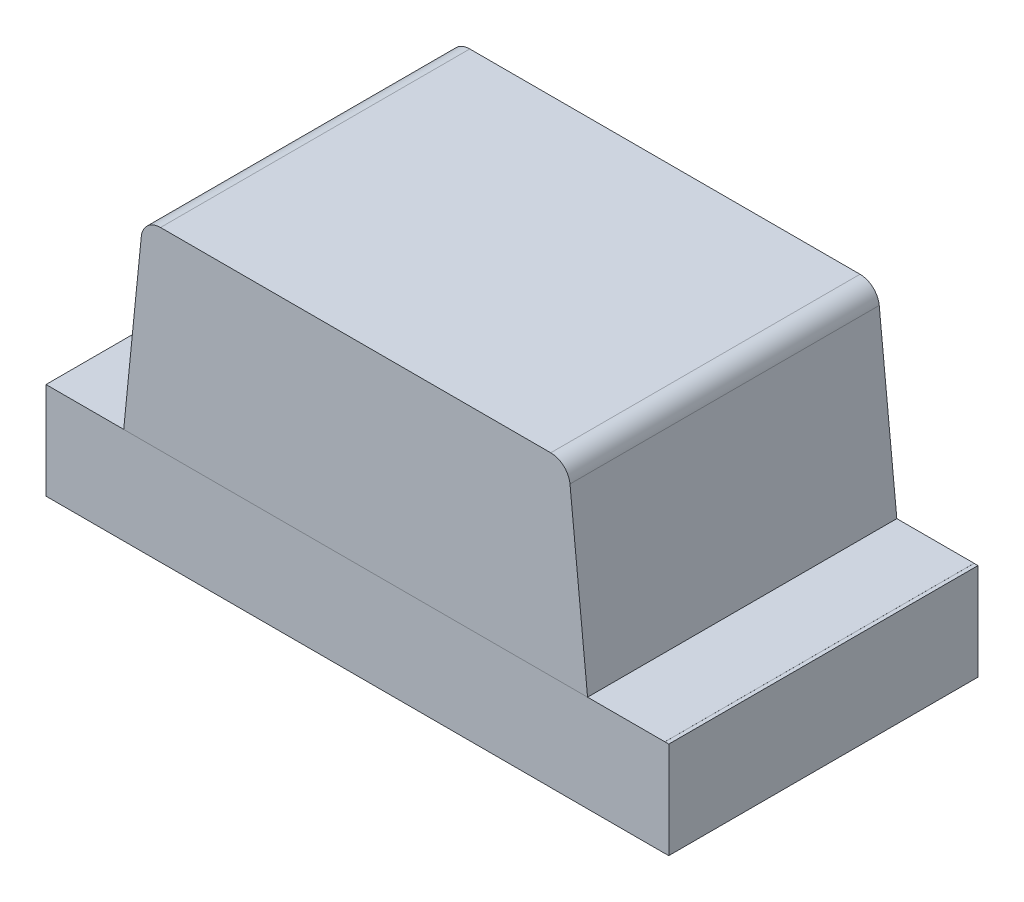
from build123d import *

# Parameters (mm, degrees)
SKETCH1_W             = 1.6
SKETCH1_H             = 0.25
EXTRUDE1_DEPTH        = 0.4
EXTRUDE2_DEPTH        = 0.4
EXTRUDE3_DEPTH        = 0.0001
EXTRUDE3_DEPTH_BACK   = 0.01
SKETCH2_3_W           = 0.3
SKETCH2_3_H           = 0.8
EXTRUDE4_DEPTH        = 0.0001
EXTRUDE4_DEPTH_BACK   = 0.01
EXTRUDE4_2_DEPTH      = 0.0001
EXTRUDE4_2_DEPTH_BACK = 0.01
SKETCH3_W             = 0.2
SKETCH3_H             = 0.8
EXTRUDE5_DEPTH        = 0.0001
EXTRUDE5_DEPTH_BACK   = 0.01
EXTRUDE5_2_DEPTH      = 0.0001
EXTRUDE5_2_DEPTH_BACK = 0.01
FILLET1_R             = 0.05
SKETCH5_W             = 0.8
SKETCH5_H             = 0.25
EXTRUDE6_DEPTH        = 0.01
EXTRUDE6_DEPTH_BACK   = 0.0001
SKETCH6_W             = 0.8
SKETCH6_H             = 0.2502
EXTRUDE7_DEPTH        = 0.001
EXTRUDE7_DEPTH_BACK   = 0.01
SKETCH7_W             = 0.013291139
SKETCH7_H             = 0.012658227
SKETCH7_H_2           = 0.012658228
CUT_EXTRUDE1_DEPTH    = 0.01


with BuildPart() as part:
    # Sketch1 → Extrude1 (new body, symmetric)
    with BuildSketch(Plane.XY):
        Rectangle(SKETCH1_W, SKETCH1_H)
    extrude(amount=EXTRUDE1_DEPTH, both=True)



with BuildPart() as body_2:
    # Sketch1_3 → Extrude2 (new body, symmetric)
    with BuildSketch(Plane.XY):
        Polygon((-0.55, 0.625), (-0.6, 0.125), (0.6, 0.125), (0.55, 0.625), align=None)
    extrude(amount=EXTRUDE2_DEPTH, both=True)

    # Fillet1
    fillet1_edges = [body_2.edges().sort_by_distance(p)[0] for p in [
        (-0.55, 0.625, 0),
        (0.55, 0.625, 0),
    ]]
    fillet(fillet1_edges, radius=FILLET1_R)


with BuildPart() as body_3:
    # Sketch2 → Extrude3 (new body, two sides)
    with BuildSketch(Plane.XZ.offset(0.125)) as extrude3_sk:
        Polygon((-0.339833711, 0.4), (-0.339833711, -0.4), (0.32532124, 0), align=None)
    extrude(amount=EXTRUDE3_DEPTH)
    extrude(extrude3_sk.sketch, amount=-EXTRUDE3_DEPTH_BACK)


with BuildPart() as body_4:
    # Sketch2_3 → Extrude4 (new body, two sides)
    with BuildSketch(Plane.XZ.offset(0.125)) as extrude4_sk:
        with Locations((-0.65, 0)):
            Rectangle(SKETCH2_3_W, SKETCH2_3_H)
    extrude(amount=EXTRUDE4_DEPTH)
    extrude(extrude4_sk.sketch, amount=-EXTRUDE4_DEPTH_BACK)


with BuildPart() as body_5:
    # Sketch2_3 → Extrude4 2 (new body, two sides)
    with BuildSketch(Plane.XZ.offset(0.125)) as extrude4_2_sk:
        with Locations((0.65, 0)):
            Rectangle(SKETCH2_3_W, SKETCH2_3_H)
    extrude(amount=EXTRUDE4_2_DEPTH)
    extrude(extrude4_2_sk.sketch, amount=-EXTRUDE4_2_DEPTH_BACK)


with BuildPart() as body_6:
    # Sketch3 → Extrude5 (new body, two sides)
    with BuildSketch(Plane(origin=(0, 0.125, 0), x_dir=(-1, 0, 0), z_dir=(0, 1, 0))) as extrude5_sk:
        with Locations((0.7, 0)):
            Rectangle(SKETCH3_W, SKETCH3_H)
    extrude(amount=EXTRUDE5_DEPTH)
    extrude(extrude5_sk.sketch, amount=-EXTRUDE5_DEPTH_BACK)


with BuildPart() as body_7:
    # Sketch3 → Extrude5 2 (new body, two sides)
    with BuildSketch(Plane(origin=(0, 0.125, 0), x_dir=(-1, 0, 0), z_dir=(0, 1, 0))) as extrude5_2_sk:
        with Locations((-0.7, 0)):
            Rectangle(SKETCH3_W, SKETCH3_H)
    extrude(amount=EXTRUDE5_2_DEPTH)
    extrude(extrude5_2_sk.sketch, amount=-EXTRUDE5_2_DEPTH_BACK)


with BuildPart() as part_1:
    add(part.part)

    add(body_5.part)  # Extrude6 merges body 5

    add(body_7.part)  # Extrude6 merges body 7
    # Sketch5 → Extrude6 (add, two sides)
    with BuildSketch(Plane(origin=(0.8, 0, 0), x_dir=(0, 0, -1), z_dir=(1, 0, 0))) as extrude6_sk:
        Rectangle(SKETCH5_W, SKETCH5_H)
    extrude(amount=EXTRUDE6_DEPTH)
    extrude(extrude6_sk.sketch, amount=-EXTRUDE6_DEPTH_BACK)


    add(body_4.part)  # Extrude7 merges body 4

    add(body_6.part)  # Extrude7 merges body 6
    # Sketch6 → Extrude7 (add, two sides)
    with BuildSketch(Plane.ZY.offset(0.8)) as extrude7_sk:
        Rectangle(SKETCH6_W, SKETCH6_H)
    extrude(amount=EXTRUDE7_DEPTH)
    extrude(extrude7_sk.sketch, amount=-EXTRUDE7_DEPTH_BACK)

    # Sketch7 → Cut-Extrude1 (cut)
    with BuildSketch(Plane.XZ.offset(0.1251)):
        Polygon((-0.707001992, 0.286075949), (-0.744343764, 0.297804589), (-0.744343764, 0.310176028), (-0.719175647, 0.318384098), (-0.744343764, 0.326147152), (-0.744343764, 0.339013054), (-0.707001992, 0.350632911), (-0.707001992, 0.338043908), (-0.732743685, 0.331546677), (-0.707001992, 0.323338608), (-0.707001992, 0.312589003), (-0.732743685, 0.30443038), (-0.707001992, 0.298022152), align=None)
        Polygon((-0.707001992, 0.218987342), (-0.744343764, 0.230715981), (-0.744343764, 0.243087421), (-0.719175647, 0.251295491), (-0.744343764, 0.259058544), (-0.744343764, 0.271924446), (-0.707001992, 0.283544304), (-0.707001992, 0.270955301), (-0.732743685, 0.26445807), (-0.707001992, 0.25625), (-0.707001992, 0.245500396), (-0.732743685, 0.237341772), (-0.707001992, 0.230933544), align=None)
        Polygon((-0.707001992, 0.151898734), (-0.744343764, 0.163627373), (-0.744343764, 0.175998813), (-0.719175647, 0.184206883), (-0.744343764, 0.191969937), (-0.744343764, 0.204835839), (-0.707001992, 0.216455696), (-0.707001992, 0.203866693), (-0.732743685, 0.197369462), (-0.707001992, 0.189161392), (-0.707001992, 0.178411788), (-0.732743685, 0.170253165), (-0.707001992, 0.163844937), align=None)
        with Locations((-0.737698195, 0.137974684)):
            Rectangle(SKETCH7_W, SKETCH7_H)
        with BuildLine():
            add(Edge.make_bspline(
                [(-0.728758321, 0.079746835), (-0.729369388, 0.079765085), (-0.73056932, 0.07980092), (-0.732323163, 0.080105713), (-0.733985315, 0.080602697), (-0.735567388, 0.081288866), (-0.737052132, 0.082185594), (-0.738453578, 0.08327723), (-0.73975585, 0.084571671), (-0.740974038, 0.086045073), (-0.742065093, 0.087693545), (-0.74301811, 0.089492402), (-0.743815446, 0.091432415), (-0.744484978, 0.093506521), (-0.744979195, 0.095729794), (-0.745341189, 0.098088543), (-0.745577848, 0.100585257), (-0.745598831, 0.102297046), (-0.745609587, 0.103174446)],
                knots=[0, 0, 0, 0, 0.907312236, 1.78165839, 2.635367075, 3.479697475, 4.336364812, 5.205276731, 6.11257575, 7.058770404, 8.040786331, 9.044147278, 10.078219212, 11.153049307, 12.278104542, 13.457648573, 14.696882856, 16, 16, 16, 16], degree=3))
            add(Edge.make_bspline(
                [(-0.745609587, 0.103174446), (-0.745597551, 0.104183574), (-0.745574239, 0.106138165), (-0.745359939, 0.108969928), (-0.74503687, 0.111603946), (-0.744553599, 0.114051804), (-0.743953216, 0.116354103), (-0.74330757, 0.118570737), (-0.742575363, 0.120711393), (-0.742025284, 0.122097938), (-0.741752783, 0.12278481)],
                knots=[0, 0, 0, 0, 1.203215828, 2.33052265, 3.384689099, 4.366106119, 5.303329643, 6.221311756, 7.118865988, 8, 8, 8, 8], degree=3))
            Line((-0.741752783, 0.12278481), (-0.729786802, 0.12278481))
            Line((-0.729786802, 0.12278481), (-0.729786802, 0.121360759))
            add(Edge.make_bspline(
                [(-0.729786802, 0.121360759), (-0.73032753, 0.120678102), (-0.73140581, 0.119316796), (-0.732787113, 0.11710018), (-0.733988194, 0.114776357), (-0.734975195, 0.112353621), (-0.735768357, 0.109905199), (-0.736315121, 0.10746751), (-0.736688795, 0.105084716), (-0.736729049, 0.103505432), (-0.736748828, 0.10272943)],
                knots=[0, 0, 0, 0, 1.030622468, 2.055194264, 3.087043286, 4.125157485, 5.149848264, 6.130935704, 7.081611712, 8, 8, 8, 8], degree=3))
            add(Edge.make_bspline(
                [(-0.736748828, 0.10272943), (-0.73674838, 0.102515041), (-0.736747423, 0.10205605), (-0.736683001, 0.101322032), (-0.73663642, 0.100492732), (-0.736531811, 0.099603299), (-0.736422519, 0.09870789), (-0.736232359, 0.09788056), (-0.73605144, 0.097128741), (-0.735867351, 0.0966755), (-0.735779682, 0.096459652)],
                knots=[0, 0, 0, 0, 0.806378557, 1.726393851, 2.771014456, 3.931269413, 5.096090628, 6.161710732, 7.124547685, 8, 8, 8, 8], degree=3))
            add(Edge.make_bspline(
                [(-0.735779682, 0.096459652), (-0.73566577, 0.096219758), (-0.735441909, 0.095748317), (-0.735033106, 0.095100857), (-0.734597455, 0.094509521), (-0.734114745, 0.093978791), (-0.733525791, 0.093553657), (-0.732825363, 0.093239557), (-0.732000213, 0.09306801), (-0.731412708, 0.093048363), (-0.731102071, 0.093037975)],
                knots=[0, 0, 0, 0, 1.024407818, 2.013179384, 2.949802342, 3.859052226, 4.77034807, 5.732977883, 6.801339628, 8, 8, 8, 8], degree=3))
            add(Edge.make_bspline(
                [(-0.731102071, 0.093037975), (-0.730829123, 0.093053696), (-0.730292427, 0.093084607), (-0.729528429, 0.093375503), (-0.72881749, 0.093816952), (-0.728187133, 0.094460463), (-0.727608414, 0.095257502), (-0.727123265, 0.09623537), (-0.726683228, 0.09736186), (-0.726474594, 0.098184089), (-0.726365125, 0.098615506)],
                knots=[0, 0, 0, 0, 0.825212765, 1.622611382, 2.449701629, 3.348069183, 4.336544339, 5.428209675, 6.6506027, 8, 8, 8, 8], degree=3))
            add(Edge.make_bspline(
                [(-0.726365125, 0.098615506), (-0.726141255, 0.09959987), (-0.72568266, 0.101616324), (-0.725109106, 0.104690378), (-0.72447607, 0.107755492), (-0.723871299, 0.109734848), (-0.723576359, 0.110700158)],
                knots=[0, 0, 0, 0, 0.976104583, 1.999535498, 3.024395274, 4, 4, 4, 4], degree=3))
            add(Edge.make_bspline(
                [(-0.723576359, 0.110700158), (-0.723399863, 0.111219416), (-0.723056296, 0.1122302), (-0.722475484, 0.113675972), (-0.721840508, 0.115006529), (-0.721162942, 0.116226584), (-0.720425943, 0.117326245), (-0.719659249, 0.11832384), (-0.71883233, 0.119195603), (-0.71796637, 0.119969445), (-0.717040369, 0.120631102), (-0.7160683, 0.121208477), (-0.715038068, 0.121696295), (-0.713957424, 0.122100736), (-0.712817989, 0.122409273), (-0.711629552, 0.122619901), (-0.710387872, 0.122769095), (-0.709540696, 0.122779501), (-0.7091084, 0.12278481)],
                knots=[0, 0, 0, 0, 1.287286806, 2.505824366, 3.654938963, 4.74627059, 5.778586806, 6.75996495, 7.696030012, 8.595059759, 9.482019644, 10.363222407, 11.245851011, 12.154256429, 13.068444161, 14.012503255, 14.985824751, 16, 16, 16, 16], degree=3))
            add(Edge.make_bspline(
                [(-0.7091084, 0.12278481), (-0.708530328, 0.122766159), (-0.707392692, 0.122729454), (-0.70572817, 0.12242874), (-0.704153801, 0.121915445), (-0.70265207, 0.121222413), (-0.701245527, 0.120308099), (-0.699906253, 0.119215702), (-0.698670457, 0.117903678), (-0.697520291, 0.116415118), (-0.696480591, 0.114771425), (-0.695565313, 0.113001934), (-0.694796987, 0.111117289), (-0.69416004, 0.109124516), (-0.693682705, 0.107015281), (-0.693323239, 0.104796665), (-0.693116648, 0.102459771), (-0.693091023, 0.10086406), (-0.693077942, 0.100049446)],
                knots=[0, 0, 0, 0, 0.894990994, 1.761326291, 2.609044902, 3.454222546, 4.315366365, 5.200560057, 6.125081389, 7.100429509, 8.110379559, 9.133447974, 10.182136699, 11.259192205, 12.370181258, 13.528580438, 14.738335141, 16, 16, 16, 16], degree=3))
            add(Edge.make_bspline(
                [(-0.693077942, 0.100049446), (-0.693089037, 0.099215103), (-0.69311121, 0.09754783), (-0.693300199, 0.095057109), (-0.693577813, 0.092576858), (-0.693998666, 0.090144943), (-0.694486874, 0.087799665), (-0.695034772, 0.085593047), (-0.695653754, 0.083553317), (-0.696130927, 0.082266485), (-0.696361169, 0.08164557)],
                knots=[0, 0, 0, 0, 1.065403572, 2.129000689, 3.188532477, 4.251604565, 5.279552602, 6.247508681, 7.154397237, 8, 8, 8, 8], degree=3))
            Line((-0.696361169, 0.08164557), (-0.707634904, 0.08164557))
            Line((-0.707634904, 0.08164557), (-0.707634904, 0.083059731))
            add(Edge.make_bspline(
                [(-0.707634904, 0.083059731), (-0.70723473, 0.083596183), (-0.706416365, 0.084693243), (-0.705374529, 0.086523061), (-0.704395596, 0.088502179), (-0.703553517, 0.090641594), (-0.702823776, 0.092871108), (-0.702314193, 0.095162587), (-0.701993288, 0.097475669), (-0.701956901, 0.099026524), (-0.701938701, 0.099802215)],
                knots=[0, 0, 0, 0, 0.892283326, 1.824742884, 2.804416662, 3.836872171, 4.8899239, 5.931447339, 6.965372909, 8, 8, 8, 8], degree=3))
            add(Edge.make_bspline(
                [(-0.701938701, 0.099802215), (-0.701949427, 0.100350049), (-0.701970878, 0.101445657), (-0.70216622, 0.103079762), (-0.702481667, 0.104700792), (-0.702891308, 0.105721053), (-0.703095742, 0.106230222)],
                knots=[0, 0, 0, 0, 0.999146175, 1.998183711, 3.000980573, 4, 4, 4, 4], degree=3))
            add(Edge.make_bspline(
                [(-0.703095742, 0.106230222), (-0.703196476, 0.106446973), (-0.703397875, 0.106880332), (-0.703784157, 0.107483654), (-0.704248563, 0.108035989), (-0.704774559, 0.108532027), (-0.705352745, 0.108966226), (-0.705990159, 0.109273902), (-0.706671616, 0.109461838), (-0.707139231, 0.109482917), (-0.707377783, 0.109493671)],
                knots=[0, 0, 0, 0, 1.00524851, 2.009826503, 3.004679593, 4.035271301, 5.048246368, 6.034938417, 6.997532266, 8, 8, 8, 8], degree=3))
            add(Edge.make_bspline(
                [(-0.707377783, 0.109493671), (-0.707696866, 0.109476452), (-0.708306604, 0.109443548), (-0.709164502, 0.109140256), (-0.709903719, 0.108647839), (-0.710401179, 0.108067536), (-0.710749898, 0.107508972), (-0.711005153, 0.106991142), (-0.711246832, 0.106386528), (-0.711495567, 0.105700905), (-0.71174116, 0.104932741), (-0.711978934, 0.104078462), (-0.712203582, 0.103137104), (-0.712346677, 0.102479167), (-0.712421296, 0.102136076)],
                knots=[0, 0, 0, 0, 1.173816843, 2.243057204, 3.312297565, 4.415174738, 5.03266065, 5.73970059, 6.541434878, 7.433956553, 8.430083051, 9.515931566, 10.70464786, 12, 12, 12, 12], degree=3))
            add(Edge.make_bspline(
                [(-0.712421296, 0.102136076), (-0.712609327, 0.101219681), (-0.712978766, 0.099419168), (-0.71353051, 0.096718577), (-0.714167994, 0.09396719), (-0.714742396, 0.092134526), (-0.715041945, 0.091178797)],
                knots=[0, 0, 0, 0, 0.995744513, 1.956417928, 2.934277412, 4, 4, 4, 4], degree=3))
            add(Edge.make_bspline(
                [(-0.715041945, 0.091178797), (-0.715201567, 0.09070552), (-0.715513813, 0.089779714), (-0.716056954, 0.088459399), (-0.716643946, 0.087235869), (-0.717264711, 0.086102353), (-0.717936694, 0.085065368), (-0.718648018, 0.084118027), (-0.719411472, 0.083276117), (-0.720218086, 0.082527335), (-0.721073136, 0.081867755), (-0.721992673, 0.081301606), (-0.722967074, 0.080815492), (-0.724010174, 0.080430689), (-0.725107467, 0.080121679), (-0.726273151, 0.079910131), (-0.72749534, 0.079763139), (-0.728332628, 0.079752331), (-0.728758321, 0.079746835)],
                knots=[0, 0, 0, 0, 1.237467875, 2.420686895, 3.535046182, 4.599015201, 5.620884487, 6.594603852, 7.531477383, 8.433220087, 9.318759595, 10.202828513, 11.105163009, 12.01247538, 12.953896178, 13.926381251, 14.945733412, 16, 16, 16, 16], degree=3))
        make_face()
        with BuildLine():
            Line((-0.744343764, 0.033544304), (-0.744343764, 0.04556962))
            Line((-0.744343764, 0.04556962), (-0.740427625, 0.04556962))
            add(Edge.make_bspline(
                [(-0.740427625, 0.04556962), (-0.740831904, 0.046116275), (-0.741611349, 0.047170216), (-0.742651457, 0.048756729), (-0.74353909, 0.050269774), (-0.744318701, 0.051726519), (-0.744906393, 0.053237621), (-0.745320427, 0.054853378), (-0.745570313, 0.05660479), (-0.745596205, 0.057818238), (-0.745609587, 0.058445411)],
                knots=[0, 0, 0, 0, 1.150872466, 2.218865267, 3.209461834, 4.120482262, 5.012764827, 5.946708227, 6.938749913, 8, 8, 8, 8], degree=3))
            add(Edge.make_bspline(
                [(-0.745609587, 0.058445411), (-0.745598228, 0.058953587), (-0.745576107, 0.059943153), (-0.745403669, 0.061381773), (-0.745134843, 0.062735587), (-0.744731047, 0.063993106), (-0.744248146, 0.065175101), (-0.743608167, 0.066243876), (-0.74289308, 0.067245677), (-0.742039557, 0.068136513), (-0.74109069, 0.068944324), (-0.74002446, 0.069635599), (-0.738857998, 0.070224454), (-0.737582071, 0.070695003), (-0.736202919, 0.071072548), (-0.734713295, 0.071334514), (-0.733119731, 0.07149481), (-0.732022166, 0.07151078), (-0.731458084, 0.071518987)],
                knots=[0, 0, 0, 0, 1.109008058, 2.159558935, 3.158726032, 4.116861086, 5.039058877, 5.938775559, 6.82970133, 7.720510853, 8.624361809, 9.544451588, 10.487360536, 11.471068125, 12.508000841, 13.604731202, 14.768976642, 16, 16, 16, 16], degree=3))
            Line((-0.731458084, 0.071518987), (-0.707001992, 0.071518987))
            Line((-0.707001992, 0.071518987), (-0.707001992, 0.059493671))
            Line((-0.707001992, 0.059493671), (-0.725791549, 0.059493671))
            add(Edge.make_bspline(
                [(-0.725791549, 0.059493671), (-0.726249785, 0.059492853), (-0.727126892, 0.059491288), (-0.728379796, 0.059450118), (-0.729513882, 0.059389668), (-0.730534896, 0.059320316), (-0.731458272, 0.059193807), (-0.732291352, 0.059004953), (-0.733051153, 0.05876954), (-0.733504504, 0.058537381), (-0.73372272, 0.058425633)],
                knots=[0, 0, 0, 0, 1.361401701, 2.605856924, 3.723918663, 4.735739235, 5.645738665, 6.489217889, 7.27279937, 8, 8, 8, 8], degree=3))
            add(Edge.make_bspline(
                [(-0.73372272, 0.058425633), (-0.733922077, 0.05831063), (-0.734313997, 0.058084543), (-0.734817086, 0.057624398), (-0.73523922, 0.057085026), (-0.735567234, 0.056446225), (-0.735816709, 0.055702951), (-0.735986827, 0.054838985), (-0.736094578, 0.053846304), (-0.736108532, 0.053141795), (-0.736115916, 0.052768987)],
                knots=[0, 0, 0, 0, 0.849138082, 1.669332372, 2.503455908, 3.370611167, 4.311442699, 5.394692208, 6.621337967, 8, 8, 8, 8], degree=3))
            add(Edge.make_bspline(
                [(-0.736115916, 0.052768987), (-0.736107238, 0.052498345), (-0.736089394, 0.051941887), (-0.735973171, 0.05108623), (-0.735794834, 0.050187942), (-0.735464906, 0.04893065), (-0.734871816, 0.047347337), (-0.734194613, 0.046167686), (-0.73385128, 0.04556962)],
                knots=[0, 0, 0, 0, 0.638127216, 1.312033637, 2.033062677, 2.79661882, 4.375931797, 6, 6, 6, 6], degree=3))
            Line((-0.73385128, 0.04556962), (-0.707001992, 0.04556962))
            Line((-0.707001992, 0.04556962), (-0.707001992, 0.033544304))
            Line((-0.707001992, 0.033544304), (-0.744343764, 0.033544304))
        make_face()
        with BuildLine():
            Line((-0.744343764, -0.015189873), (-0.744343764, -0.003164557))
            Line((-0.744343764, -0.003164557), (-0.725554207, -0.003164557))
            add(Edge.make_bspline(
                [(-0.725554207, -0.003164557), (-0.724789186, -0.0031523), (-0.723263673, -0.003127858), (-0.721382468, -0.002986796), (-0.719961306, -0.002797535), (-0.719042365, -0.002612707), (-0.718268296, -0.002396857), (-0.717825416, -0.002190717), (-0.717623036, -0.002096519)],
                knots=[0, 0, 0, 0, 1.709124929, 3.408128882, 4.211124727, 4.91016634, 5.501986363, 6, 6, 6, 6], degree=3))
            add(Edge.make_bspline(
                [(-0.717623036, -0.002096519), (-0.71742401, -0.001974288), (-0.71703379, -0.001734636), (-0.716527283, -0.001265974), (-0.716112863, -0.000719031), (-0.715772088, -8.3646e-05), (-0.715536797, 0.000661952), (-0.715340182, 0.001520323), (-0.715256728, 0.002513632), (-0.715239148, 0.003217267), (-0.71522984, 0.003589794)],
                knots=[0, 0, 0, 0, 0.86006424, 1.686277094, 2.52783008, 3.38194165, 4.331801563, 5.402842185, 6.624978739, 8, 8, 8, 8], degree=3))
            add(Edge.make_bspline(
                [(-0.71522984, 0.003589794), (-0.715258209, 0.004155705), (-0.715316136, 0.005311252), (-0.715671889, 0.006742349), (-0.716081369, 0.007907651), (-0.716460784, 0.008833913), (-0.716946505, 0.009788229), (-0.717307416, 0.010427935), (-0.717494476, 0.010759494)],
                knots=[0, 0, 0, 0, 1.338371478, 2.732853438, 3.468019217, 4.261884641, 5.099136535, 6, 6, 6, 6], degree=3))
            Line((-0.717494476, 0.010759494), (-0.744343764, 0.010759494))
            Line((-0.744343764, 0.010759494), (-0.744343764, 0.02278481))
            Line((-0.744343764, 0.02278481), (-0.707001992, 0.02278481))
            Line((-0.707001992, 0.02278481), (-0.707001992, 0.010759494))
            Line((-0.707001992, 0.010759494), (-0.710918131, 0.010759494))
            add(Edge.make_bspline(
                [(-0.710918131, 0.010759494), (-0.710515056, 0.01023079), (-0.709730445, 0.009201638), (-0.708710234, 0.007612019), (-0.70781085, 0.00607007), (-0.707054441, 0.004543565), (-0.706451054, 0.002986088), (-0.706045559, 0.001354709), (-0.705773658, -0.000353494), (-0.705748811, -0.001521852), (-0.705736169, -0.002116297)],
                knots=[0, 0, 0, 0, 1.126119141, 2.192057864, 3.198061997, 4.149848529, 5.076251285, 6.021887753, 6.99356175, 8, 8, 8, 8], degree=3))
            add(Edge.make_bspline(
                [(-0.705736169, -0.002116297), (-0.705748864, -0.002614433), (-0.705773646, -0.003586883), (-0.705928501, -0.005004263), (-0.706203833, -0.006339973), (-0.706602748, -0.00758611), (-0.707095554, -0.00875742), (-0.707711311, -0.009838393), (-0.708440523, -0.010834428), (-0.709271024, -0.011748628), (-0.710215887, -0.012564037), (-0.711274519, -0.013272555), (-0.712446068, -0.013862546), (-0.713726222, -0.014347902), (-0.715108777, -0.014735114), (-0.716606759, -0.014992679), (-0.718208849, -0.015169571), (-0.71931687, -0.015182971), (-0.719887673, -0.015189873)],
                knots=[0, 0, 0, 0, 1.08848837, 2.124922927, 3.110950502, 4.063144162, 4.979605775, 5.882838355, 6.774625441, 7.671951181, 8.57587277, 9.494821853, 10.448322275, 11.435533005, 12.482327682, 13.580118324, 14.753386918, 16, 16, 16, 16], degree=3))
            Line((-0.719887673, -0.015189873), (-0.744343764, -0.015189873))
        make_face()
        Polygon((-0.744343764, -0.062658228), (-0.744343764, -0.026582278), (-0.694343764, -0.026582278), (-0.694343764, -0.039240506), (-0.734850093, -0.039240506), (-0.734850093, -0.062658228), align=None)
        Polygon((-0.744343764, -0.106329114), (-0.744343764, -0.070253165), (-0.694343764, -0.070253165), (-0.694343764, -0.106329114), (-0.703837435, -0.106329114), (-0.703837435, -0.082911392), (-0.712698195, -0.082911392), (-0.712698195, -0.10443038), (-0.722191866, -0.10443038), (-0.722191866, -0.082911392), (-0.734850093, -0.082911392), (-0.734850093, -0.106329114), align=None)
        with BuildLine():
            add(Edge.make_bspline(
                [(-0.719393211, -0.164556962), (-0.719967055, -0.164547304), (-0.721103498, -0.164528178), (-0.722785901, -0.164380583), (-0.724418739, -0.16411757), (-0.726010863, -0.163777979), (-0.727550327, -0.163316726), (-0.729054116, -0.16277587), (-0.730506863, -0.162121047), (-0.73190758, -0.16136862), (-0.733243631, -0.160543884), (-0.734503736, -0.15965651), (-0.735695344, -0.15873362), (-0.736792791, -0.157738964), (-0.737813801, -0.156699373), (-0.738759208, -0.155611609), (-0.739610924, -0.154459076), (-0.740122366, -0.153655495), (-0.740378179, -0.15325356)],
                knots=[0, 0, 0, 0, 1.105570398, 2.18947457, 3.250358341, 4.290584537, 5.323553275, 6.344225964, 7.367641686, 8.3905646, 9.405808457, 10.390761353, 11.358902336, 12.307789878, 13.241960776, 14.165076779, 15.082208636, 16, 16, 16, 16], degree=3))
            add(Edge.make_bspline(
                [(-0.740378179, -0.15325356), (-0.740734249, -0.152633946), (-0.741448205, -0.151391556), (-0.7422825, -0.149399639), (-0.742984558, -0.147336898), (-0.74351177, -0.145161705), (-0.743875292, -0.1428382), (-0.744155696, -0.140337495), (-0.744306575, -0.1376337), (-0.744331085, -0.135766253), (-0.744343764, -0.134800237)],
                knots=[0, 0, 0, 0, 0.896288622, 1.797150563, 2.705281913, 3.629615989, 4.602417572, 5.655716007, 6.787320449, 8, 8, 8, 8], degree=3))
            Line((-0.744343764, -0.134800237), (-0.744343764, -0.117088608))
            Line((-0.744343764, -0.117088608), (-0.694343764, -0.117088608))
            Line((-0.694343764, -0.117088608), (-0.694343764, -0.135304589))
            add(Edge.make_bspline(
                [(-0.694343764, -0.135304589), (-0.69435207, -0.136293955), (-0.69436809, -0.138202319), (-0.694576885, -0.140960738), (-0.694875297, -0.143513342), (-0.695337733, -0.145856016), (-0.695895405, -0.148006019), (-0.69657497, -0.149968756), (-0.697324323, -0.151774643), (-0.69796117, -0.152864064), (-0.698269793, -0.153392009)],
                knots=[0, 0, 0, 0, 1.267175336, 2.444223962, 3.542125549, 4.557526608, 5.500936977, 6.385043188, 7.217374394, 8, 8, 8, 8], degree=3))
            add(Edge.make_bspline(
                [(-0.698269793, -0.153392009), (-0.698538063, -0.153817486), (-0.69907152, -0.154663548), (-0.699962446, -0.155864156), (-0.700940485, -0.156978869), (-0.701966394, -0.158043121), (-0.703067837, -0.15903303), (-0.704237191, -0.159954629), (-0.705476238, -0.160806538), (-0.706780972, -0.16158552), (-0.708145998, -0.162295927), (-0.709582528, -0.16289058), (-0.711071793, -0.163415255), (-0.712626274, -0.163818023), (-0.714230192, -0.16416698), (-0.715900864, -0.164384347), (-0.717627108, -0.164527653), (-0.718799553, -0.16454711), (-0.719393211, -0.164556962)],
                knots=[0, 0, 0, 0, 0.964065863, 1.917049184, 2.86229036, 3.805247319, 4.749389377, 5.698846072, 6.657678277, 7.629829384, 8.610569287, 9.604676042, 10.607940105, 11.6349849, 12.681042988, 13.752616828, 14.862056989, 16, 16, 16, 16], degree=3))
        make_face()
        with BuildLine():
            add(Edge.make_bspline(
                [(-0.719314097, -0.151265823), (-0.718911717, -0.151260702), (-0.718122425, -0.151250659), (-0.716964667, -0.151154875), (-0.715849842, -0.151025347), (-0.714782496, -0.15080982), (-0.713752711, -0.150559996), (-0.712773964, -0.150238922), (-0.711834177, -0.149876723), (-0.710945433, -0.149435904), (-0.710091242, -0.148949086), (-0.709298484, -0.148375339), (-0.708542041, -0.14775117), (-0.707828049, -0.147062027), (-0.707175101, -0.146290557), (-0.706560063, -0.145460506), (-0.7059959, -0.144560327), (-0.705665875, -0.143923833), (-0.705498828, -0.143601661)],
                knots=[0, 0, 0, 0, 1.152093354, 2.259898929, 3.325467225, 4.364140538, 5.376172865, 6.358396836, 7.312077728, 8.257828931, 9.196960457, 10.124297759, 11.056236784, 12.004246951, 12.961658638, 13.947279359, 14.960983522, 16, 16, 16, 16], degree=3))
            add(Edge.make_bspline(
                [(-0.705498828, -0.143601661), (-0.705345472, -0.143264213), (-0.705041509, -0.142595365), (-0.704675913, -0.141559954), (-0.704389495, -0.140515262), (-0.704174066, -0.139414463), (-0.704013101, -0.138179583), (-0.703914472, -0.136716792), (-0.703843387, -0.134988837), (-0.703839511, -0.13374548), (-0.703837435, -0.133079509)],
                knots=[0, 0, 0, 0, 0.826967603, 1.639107464, 2.447640171, 3.242670507, 4.14065217, 5.225198036, 6.513753944, 8, 8, 8, 8], degree=3))
            Line((-0.703837435, -0.133079509), (-0.703837435, -0.129746835))
            Line((-0.703837435, -0.129746835), (-0.734850093, -0.129746835))
            Line((-0.734850093, -0.129746835), (-0.734850093, -0.133079509))
            add(Edge.make_bspline(
                [(-0.734850093, -0.133079509), (-0.734847719, -0.133458613), (-0.734843134, -0.134190496), (-0.734821603, -0.135248617), (-0.734798159, -0.136231516), (-0.734739928, -0.137133951), (-0.734703605, -0.137963293), (-0.734614415, -0.138706684), (-0.734543325, -0.139377929), (-0.734409464, -0.140161727), (-0.734201372, -0.14108831), (-0.733862283, -0.14216894), (-0.733437085, -0.143239207), (-0.733094602, -0.143933494), (-0.732921692, -0.144284019)],
                knots=[0, 0, 0, 0, 1.186793418, 2.291178421, 3.313283093, 4.264083014, 5.122158624, 5.910777728, 6.607099052, 7.234812932, 8.398911528, 9.577194775, 10.776795607, 12, 12, 12, 12], degree=3))
            add(Edge.make_bspline(
                [(-0.732921692, -0.144284019), (-0.732750933, -0.144576577), (-0.732414176, -0.14515354), (-0.731847139, -0.145965292), (-0.731243277, -0.146719151), (-0.730599051, -0.147417157), (-0.729904931, -0.148048807), (-0.72917166, -0.148624816), (-0.728397671, -0.149140041), (-0.727300912, -0.149757735), (-0.725785444, -0.150369358), (-0.72380175, -0.15088913), (-0.721621869, -0.151207565), (-0.72010306, -0.151245906), (-0.719314097, -0.151265823)],
                knots=[0, 0, 0, 0, 0.755160452, 1.489275589, 2.205657296, 2.907868421, 3.605098304, 4.296256403, 4.985378686, 5.676536785, 7.100390329, 8.614249252, 10.241231541, 12, 12, 12, 12], degree=3))
        make_face(mode=Mode.SUBTRACT)
        with Locations((-0.737698195, -0.180379747)):
            Rectangle(SKETCH7_W, SKETCH7_H_2)
        with BuildLine():
            add(Edge.make_bspline(
                [(-0.745609587, -0.217701741), (-0.745598682, -0.216906684), (-0.745577276, -0.215346116), (-0.745338817, -0.213060445), (-0.74497997, -0.210877859), (-0.744469516, -0.208804705), (-0.743795768, -0.206847809), (-0.7429693, -0.20501599), (-0.741976708, -0.203312562), (-0.741187104, -0.202283238), (-0.740793527, -0.201770174)],
                knots=[0, 0, 0, 0, 1.123670284, 2.205584497, 3.245308791, 4.249063313, 5.220352711, 6.167273909, 7.086481357, 8, 8, 8, 8], degree=3))
            add(Edge.make_bspline(
                [(-0.740793527, -0.201770174), (-0.74036614, -0.2012943), (-0.739513018, -0.200344393), (-0.738027305, -0.199111426), (-0.736385783, -0.198049884), (-0.734584672, -0.197157107), (-0.732626307, -0.196441646), (-0.730503976, -0.195930079), (-0.728223586, -0.195620456), (-0.726649619, -0.195586873), (-0.725840995, -0.19556962)],
                knots=[0, 0, 0, 0, 0.916457077, 1.82937027, 2.759194969, 3.714948755, 4.706655623, 5.743329475, 6.840637961, 8, 8, 8, 8], degree=3))
            add(Edge.make_bspline(
                [(-0.725840995, -0.19556962), (-0.724989382, -0.195589), (-0.723338842, -0.195626562), (-0.720952748, -0.195958442), (-0.718743908, -0.196493248), (-0.716717954, -0.197262027), (-0.714871358, -0.198227248), (-0.71318544, -0.199359494), (-0.711663978, -0.200669757), (-0.710791259, -0.201673326), (-0.710354445, -0.202175633)],
                knots=[0, 0, 0, 0, 1.171797512, 2.271099083, 3.308930235, 4.294129479, 5.24602549, 6.17106565, 7.084581485, 8, 8, 8, 8], degree=3))
            add(Edge.make_bspline(
                [(-0.710354445, -0.202175633), (-0.709970152, -0.202688568), (-0.709196924, -0.203720634), (-0.708246574, -0.205422386), (-0.707449181, -0.207233994), (-0.706825359, -0.209148779), (-0.706348406, -0.211135184), (-0.705986484, -0.213165013), (-0.705776205, -0.21523814), (-0.705749579, -0.21663324), (-0.705736169, -0.217335839)],
                knots=[0, 0, 0, 0, 0.952130878, 1.915761808, 2.890227217, 3.891541892, 4.905612075, 5.925811839, 6.955400088, 8, 8, 8, 8], degree=3))
            add(Edge.make_bspline(
                [(-0.705736169, -0.217335839), (-0.705744671, -0.217959198), (-0.705761387, -0.219184934), (-0.705922441, -0.220985457), (-0.706189001, -0.222712728), (-0.706558302, -0.224365194), (-0.707004104, -0.225952167), (-0.707523674, -0.227477255), (-0.708090308, -0.228957161), (-0.708532576, -0.229907445), (-0.708752388, -0.230379747)],
                knots=[0, 0, 0, 0, 1.107648782, 2.178012834, 3.209595929, 4.211695017, 5.185427128, 6.137685403, 7.07440854, 8, 8, 8, 8], degree=3))
            Line((-0.708752388, -0.230379747), (-0.719027309, -0.230379747))
            Line((-0.719027309, -0.230379747), (-0.719027309, -0.228708465))
            add(Edge.make_bspline(
                [(-0.719027309, -0.228708465), (-0.718818699, -0.228458693), (-0.718367842, -0.227918875), (-0.717657465, -0.227025667), (-0.716892669, -0.225951196), (-0.716446696, -0.225124428), (-0.716208875, -0.224683544)],
                knots=[0, 0, 0, 0, 0.792826818, 1.713491785, 2.780691913, 4, 4, 4, 4], degree=3))
            add(Edge.make_bspline(
                [(-0.716208875, -0.224683544), (-0.715987896, -0.224219577), (-0.715534966, -0.223268604), (-0.715118549, -0.221990602), (-0.714834686, -0.220894601), (-0.714706475, -0.219985833), (-0.714611695, -0.219019023), (-0.714601941, -0.218351402), (-0.714596929, -0.218008307)],
                knots=[0, 0, 0, 0, 1.332524827, 2.731214173, 3.480270227, 4.267952375, 5.109889624, 6, 6, 6, 6], degree=3))
            add(Edge.make_bspline(
                [(-0.714596929, -0.218008307), (-0.714606704, -0.217625529), (-0.714625647, -0.216883724), (-0.714764175, -0.21580297), (-0.715003304, -0.214793764), (-0.715323354, -0.213842153), (-0.71576716, -0.212973121), (-0.716283979, -0.212159701), (-0.71689688, -0.211413572), (-0.717617351, -0.210753941), (-0.718407315, -0.210157578), (-0.719274373, -0.209647977), (-0.720197673, -0.209191749), (-0.721199897, -0.20884428), (-0.722264285, -0.208564411), (-0.723395845, -0.208369946), (-0.7245956, -0.208248967), (-0.725418754, -0.208235008), (-0.725840995, -0.208227848)],
                knots=[0, 0, 0, 0, 1.087302107, 2.107140881, 3.088415001, 4.030197574, 4.951552271, 5.852940509, 6.764198256, 7.685219758, 8.621679636, 9.570836121, 10.538340132, 11.542450476, 12.578202196, 13.66207107, 14.800746211, 16, 16, 16, 16], degree=3))
            add(Edge.make_bspline(
                [(-0.725840995, -0.208227848), (-0.726273074, -0.208235235), (-0.72711258, -0.208249588), (-0.728333385, -0.208366345), (-0.729474101, -0.208574291), (-0.730536761, -0.208859915), (-0.73151977, -0.209222089), (-0.732418468, -0.209674648), (-0.733246872, -0.210192826), (-0.733978178, -0.210815105), (-0.734636339, -0.211497047), (-0.735204406, -0.212254492), (-0.735678478, -0.213084112), (-0.73608071, -0.213975202), (-0.736369909, -0.214941723), (-0.736588255, -0.215969991), (-0.736732533, -0.217064769), (-0.736743315, -0.217819945), (-0.736748828, -0.218206092)],
                knots=[0, 0, 0, 0, 1.230336593, 2.390482092, 3.487897344, 4.52859895, 5.520747884, 6.465347575, 7.38981449, 8.296085817, 9.192433006, 10.084246191, 10.984321635, 11.908883871, 12.862027947, 13.850751296, 14.901019963, 16, 16, 16, 16], degree=3))
            add(Edge.make_bspline(
                [(-0.736748828, -0.218206092), (-0.736744764, -0.218569019), (-0.736736842, -0.219276532), (-0.736627803, -0.220308905), (-0.736489862, -0.221289359), (-0.736270158, -0.222207129), (-0.735998971, -0.223054762), (-0.735715717, -0.223834974), (-0.735413325, -0.224541197), (-0.735179548, -0.224971874), (-0.735067657, -0.225178006)],
                knots=[0, 0, 0, 0, 1.200823684, 2.340960236, 3.433630075, 4.476504061, 5.46014544, 6.378484521, 7.223905657, 8, 8, 8, 8], degree=3))
            add(Edge.make_bspline(
                [(-0.735067657, -0.225178006), (-0.73485271, -0.225528109), (-0.734436888, -0.226205393), (-0.733736105, -0.227124757), (-0.733028976, -0.227947191), (-0.732550867, -0.228459447), (-0.732318448, -0.228708465)],
                knots=[0, 0, 0, 0, 1.098601379, 2.125273733, 3.088655601, 4, 4, 4, 4], degree=3))
            Line((-0.732318448, -0.228708465), (-0.732318448, -0.230379747))
            Line((-0.732318448, -0.230379747), (-0.742672483, -0.230379747))
            add(Edge.make_bspline(
                [(-0.742672483, -0.230379747), (-0.74289123, -0.229907052), (-0.743328777, -0.228961548), (-0.743905713, -0.227504259), (-0.744389793, -0.226010272), (-0.744841333, -0.224486086), (-0.745185514, -0.222900044), (-0.745432075, -0.221238529), (-0.745582531, -0.21949778), (-0.745600446, -0.218308585), (-0.745609587, -0.217701741)],
                knots=[0, 0, 0, 0, 0.952012952, 1.904254716, 2.862729541, 3.822037426, 4.808956931, 5.82647221, 6.890850784, 8, 8, 8, 8], degree=3))
        make_face()
        with BuildLine():
            add(Edge.make_bspline(
                [(-0.725692657, -0.276582278), (-0.72644511, -0.276569931), (-0.727911843, -0.276545862), (-0.730047738, -0.276276203), (-0.732065737, -0.275869813), (-0.733959341, -0.275283548), (-0.735737979, -0.274543352), (-0.737382875, -0.273617882), (-0.73890949, -0.27253238), (-0.740304432, -0.271286861), (-0.741553687, -0.26988626), (-0.742651314, -0.268349169), (-0.743558035, -0.266662255), (-0.74431408, -0.2648551), (-0.744898698, -0.262912774), (-0.745305056, -0.260835664), (-0.745572791, -0.258627097), (-0.745597117, -0.257107888), (-0.745609587, -0.256329114)],
                knots=[0, 0, 0, 0, 1.120167703, 2.183507516, 3.201345984, 4.182878364, 5.131270247, 6.065524964, 6.98789854, 7.91635504, 8.84481154, 9.778033504, 10.722808862, 11.691211189, 12.691525459, 13.738229926, 14.840575679, 16, 16, 16, 16], degree=3))
            add(Edge.make_bspline(
                [(-0.745609587, -0.256329114), (-0.745597076, -0.255550353), (-0.74557267, -0.254031171), (-0.745305504, -0.251822416), (-0.744896529, -0.249742868), (-0.744318478, -0.247798215), (-0.743555204, -0.245993842), (-0.74265168, -0.244308909), (-0.741553583, -0.242772026), (-0.740304487, -0.241371283), (-0.738909374, -0.240126124), (-0.737383283, -0.239039328), (-0.735735306, -0.238118121), (-0.733963783, -0.237359195), (-0.732063364, -0.236792532), (-0.730048143, -0.236380801), (-0.727911733, -0.236112697), (-0.726445073, -0.236088409), (-0.725692657, -0.236075949)],
                knots=[0, 0, 0, 0, 1.15937715, 2.261678054, 3.308339936, 4.313313916, 5.277148057, 6.221884977, 7.155068972, 8.083487698, 9.011906424, 9.934242473, 10.868459181, 11.818729666, 12.798784262, 13.81658132, 14.879877871, 16, 16, 16, 16], degree=3))
            add(Edge.make_bspline(
                [(-0.725692657, -0.236075949), (-0.724936945, -0.236088511), (-0.72346044, -0.236113053), (-0.721311003, -0.236380738), (-0.719280678, -0.236789747), (-0.717376521, -0.237369763), (-0.715600722, -0.2381279), (-0.713949669, -0.239048412), (-0.712426382, -0.240146646), (-0.711031506, -0.241401395), (-0.709783315, -0.242807292), (-0.708696863, -0.244354258), (-0.707778534, -0.246030217), (-0.707017617, -0.247833817), (-0.706450335, -0.249777095), (-0.706041545, -0.251845566), (-0.705772509, -0.254044263), (-0.705748503, -0.255553632), (-0.705736169, -0.256329114)],
                knots=[0, 0, 0, 0, 1.124034801, 2.196132384, 3.217834281, 4.203147447, 5.152578239, 6.085969439, 7.010345409, 7.941219594, 8.872481455, 9.802010446, 10.748267785, 11.711250247, 12.709230373, 13.754967386, 14.846549946, 16, 16, 16, 16], degree=3))
            add(Edge.make_bspline(
                [(-0.705736169, -0.256329114), (-0.70574853, -0.257114483), (-0.705772597, -0.258643565), (-0.706040698, -0.260865271), (-0.706447201, -0.262952191), (-0.707030399, -0.264901503), (-0.707786106, -0.266714378), (-0.708703434, -0.268394416), (-0.709804463, -0.269930069), (-0.711058041, -0.271323696), (-0.712460742, -0.272563817), (-0.713985554, -0.273648275), (-0.715645412, -0.274551884), (-0.717422846, -0.275292769), (-0.719319731, -0.275878856), (-0.721336783, -0.276289348), (-0.723474282, -0.276542343), (-0.724940347, -0.276568735), (-0.725692657, -0.276582278)],
                knots=[0, 0, 0, 0, 1.167358552, 2.272800965, 3.322628764, 4.326027541, 5.29287265, 6.238482395, 7.166210353, 8.096447471, 9.020151799, 9.945039072, 10.873038967, 11.824425184, 12.804379233, 13.820580988, 14.881633558, 16, 16, 16, 16], degree=3))
        make_face()
        with BuildLine():
            add(Edge.make_bspline(
                [(-0.734939097, -0.261728639), (-0.734689093, -0.261906228), (-0.734180307, -0.262267642), (-0.733330096, -0.262702769), (-0.732419198, -0.263096771), (-0.731404558, -0.263405869), (-0.730253335, -0.263645529), (-0.728926539, -0.263801225), (-0.727408782, -0.263916047), (-0.726332426, -0.263921278), (-0.725761881, -0.263924051)],
                knots=[0, 0, 0, 0, 0.764956307, 1.556776596, 2.379454426, 3.241401993, 4.200532455, 5.312591107, 6.575484591, 8, 8, 8, 8], degree=3))
            add(Edge.make_bspline(
                [(-0.725761881, -0.263924051), (-0.725224441, -0.263915206), (-0.724194762, -0.263898261), (-0.722714881, -0.263805076), (-0.721373168, -0.263630739), (-0.72016447, -0.2633818), (-0.719079126, -0.263076915), (-0.718107945, -0.262713947), (-0.717248644, -0.262294688), (-0.716746028, -0.261951955), (-0.716505552, -0.261787975)],
                knots=[0, 0, 0, 0, 1.337076348, 2.561692668, 3.686680134, 4.69989255, 5.629188848, 6.488203485, 7.276684665, 8, 8, 8, 8], degree=3))
            add(Edge.make_bspline(
                [(-0.716505552, -0.261787975), (-0.716285911, -0.261619326), (-0.715855033, -0.261288481), (-0.71531394, -0.260700455), (-0.714864793, -0.260068176), (-0.714534773, -0.259378025), (-0.714275144, -0.258655442), (-0.714101726, -0.257901279), (-0.713987665, -0.257123703), (-0.713971976, -0.256596534), (-0.713964017, -0.256329114)],
                knots=[0, 0, 0, 0, 1.058684453, 2.076859345, 3.046867319, 4.017860406, 4.996047344, 5.981941452, 6.976284511, 8, 8, 8, 8], degree=3))
            add(Edge.make_bspline(
                [(-0.713964017, -0.256329114), (-0.713969491, -0.256065148), (-0.713980196, -0.255548839), (-0.714070037, -0.254797507), (-0.714217332, -0.254092033), (-0.714426298, -0.253422095), (-0.71472404, -0.252776108), (-0.715152252, -0.252158936), (-0.715689917, -0.251550968), (-0.716115177, -0.251181844), (-0.716337435, -0.250988924)],
                knots=[0, 0, 0, 0, 1.041978199, 2.038073998, 2.982578265, 3.884042198, 4.804014415, 5.778706634, 6.839057036, 8, 8, 8, 8], degree=3))
            add(Edge.make_bspline(
                [(-0.716337435, -0.250988924), (-0.716574748, -0.250822182), (-0.717074049, -0.25047136), (-0.717926309, -0.250029872), (-0.718907269, -0.249664195), (-0.719999139, -0.249318075), (-0.721234713, -0.249058943), (-0.722611352, -0.248858574), (-0.724138566, -0.248758217), (-0.725204675, -0.248742429), (-0.725761881, -0.248734177)],
                knots=[0, 0, 0, 0, 0.706185926, 1.485796665, 2.33004681, 3.254820698, 4.274138656, 5.402098861, 6.642194297, 8, 8, 8, 8], degree=3))
            add(Edge.make_bspline(
                [(-0.725761881, -0.248734177), (-0.726263113, -0.24873875), (-0.727233669, -0.248747606), (-0.728636862, -0.248847063), (-0.729938828, -0.249011401), (-0.731133844, -0.249249723), (-0.732226293, -0.249536845), (-0.733202123, -0.249910582), (-0.734079651, -0.250322319), (-0.734593522, -0.250672488), (-0.734840204, -0.250840585)],
                knots=[0, 0, 0, 0, 1.270915159, 2.460926195, 3.565223763, 4.596447547, 5.549594966, 6.425286377, 7.244063354, 8, 8, 8, 8], degree=3))
            add(Edge.make_bspline(
                [(-0.734840204, -0.250840585), (-0.735048447, -0.251010866), (-0.735459011, -0.251346584), (-0.736001019, -0.251921043), (-0.736431694, -0.252562899), (-0.736796938, -0.253238501), (-0.737061562, -0.253969402), (-0.737249865, -0.254745348), (-0.737357742, -0.255571215), (-0.737373606, -0.256137613), (-0.737381739, -0.256428006)],
                knots=[0, 0, 0, 0, 1.011121112, 1.993489184, 2.956264801, 3.910060304, 4.874908638, 5.87009835, 6.907993364, 8, 8, 8, 8], degree=3))
            add(Edge.make_bspline(
                [(-0.737381739, -0.256428006), (-0.737354948, -0.256928481), (-0.737301487, -0.257927162), (-0.736945661, -0.259134737), (-0.736521021, -0.260038399), (-0.736081393, -0.260658034), (-0.735561624, -0.261236129), (-0.735148635, -0.261562864), (-0.734939097, -0.261728639)],
                knots=[0, 0, 0, 0, 1.48399549, 2.96126462, 3.700919455, 4.439278468, 5.208134679, 6, 6, 6, 6], degree=3))
        make_face(mode=Mode.SUBTRACT)
        with BuildLine():
            Line((-0.717494476, -0.322151899), (-0.744343764, -0.322151899))
            Line((-0.744343764, -0.322151899), (-0.744343764, -0.310126582))
            Line((-0.744343764, -0.310126582), (-0.725415758, -0.310126582))
            add(Edge.make_bspline(
                [(-0.725415758, -0.310126582), (-0.724970741, -0.310123849), (-0.724116925, -0.310118605), (-0.722887118, -0.310102093), (-0.721762816, -0.310061957), (-0.720739717, -0.310008188), (-0.719809984, -0.309914716), (-0.718972566, -0.309759046), (-0.718219803, -0.309548298), (-0.71776933, -0.309344122), (-0.717553812, -0.30924644)],
                knots=[0, 0, 0, 0, 1.339742217, 2.570446543, 3.702449567, 4.726327994, 5.654556215, 6.512888379, 7.288529137, 8, 8, 8, 8], degree=3))
            add(Edge.make_bspline(
                [(-0.717553812, -0.30924644), (-0.717361128, -0.309141477), (-0.716979182, -0.308933415), (-0.716495251, -0.308499392), (-0.716089929, -0.307995238), (-0.715769201, -0.307405157), (-0.71552012, -0.306715815), (-0.715345447, -0.305908255), (-0.715255246, -0.304976326), (-0.715238628, -0.304315182), (-0.71522984, -0.303965585)],
                knots=[0, 0, 0, 0, 0.859345536, 1.703436662, 2.532498256, 3.390183975, 4.328249457, 5.402602062, 6.626559876, 8, 8, 8, 8], degree=3))
            add(Edge.make_bspline(
                [(-0.71522984, -0.303965585), (-0.715241621, -0.303671938), (-0.71526529, -0.303081995), (-0.71538606, -0.302202758), (-0.715637032, -0.301343152), (-0.716055351, -0.300233813), (-0.716663585, -0.298929162), (-0.717224529, -0.297942954), (-0.717494476, -0.297468354)],
                knots=[0, 0, 0, 0, 0.759443456, 1.525737455, 2.286422378, 3.068189154, 4.58910569, 6, 6, 6, 6], degree=3))
            Line((-0.717494476, -0.297468354), (-0.744343764, -0.297468354))
            Line((-0.744343764, -0.297468354), (-0.744343764, -0.285443038))
            Line((-0.744343764, -0.285443038), (-0.707001992, -0.285443038))
            Line((-0.707001992, -0.285443038), (-0.707001992, -0.297468354))
            Line((-0.707001992, -0.297468354), (-0.710918131, -0.297468354))
            add(Edge.make_bspline(
                [(-0.710918131, -0.297468354), (-0.710527391, -0.297978873), (-0.70976873, -0.298970094), (-0.708745762, -0.30047708), (-0.707864045, -0.301954822), (-0.707098766, -0.30340538), (-0.706471075, -0.304878603), (-0.706052692, -0.306425853), (-0.705786532, -0.308047227), (-0.705753161, -0.309156368), (-0.705736169, -0.309721123)],
                knots=[0, 0, 0, 0, 1.136140478, 2.205924536, 3.217129804, 4.176128364, 5.103417168, 6.04061054, 7.002313223, 8, 8, 8, 8], degree=3))
            add(Edge.make_bspline(
                [(-0.705736169, -0.309721123), (-0.705752042, -0.310322745), (-0.705783064, -0.311498573), (-0.706117695, -0.313204533), (-0.706620007, -0.314812477), (-0.707365224, -0.31629048), (-0.708281624, -0.317651552), (-0.709420478, -0.318847043), (-0.710743381, -0.319904312), (-0.711749199, -0.320449376), (-0.712263068, -0.320727848)],
                knots=[0, 0, 0, 0, 1.06605855, 2.083537511, 3.073064962, 4.046068917, 5.009676085, 5.97370914, 6.964773701, 8, 8, 8, 8], degree=3))
            add(Edge.make_bspline(
                [(-0.712263068, -0.320727848), (-0.711774588, -0.321318891), (-0.710822636, -0.322470721), (-0.709551288, -0.324247517), (-0.708424138, -0.325987096), (-0.707469281, -0.327707222), (-0.706696837, -0.329405047), (-0.706144037, -0.331094611), (-0.705802314, -0.332769002), (-0.705757963, -0.333885631), (-0.705736169, -0.334434335)],
                knots=[0, 0, 0, 0, 1.188124574, 2.315425566, 3.384037189, 4.39937427, 5.362203716, 6.270239573, 7.150007311, 8, 8, 8, 8], degree=3))
            add(Edge.make_bspline(
                [(-0.705736169, -0.334434335), (-0.705747857, -0.334925965), (-0.705770597, -0.335882544), (-0.705938245, -0.337273765), (-0.706223614, -0.338572059), (-0.70662074, -0.339783342), (-0.707132449, -0.340904963), (-0.707769363, -0.34193039), (-0.708522454, -0.342857681), (-0.709372357, -0.343704126), (-0.71033953, -0.34444479), (-0.71140336, -0.345096597), (-0.71257887, -0.345620785), (-0.713842927, -0.346073393), (-0.715211566, -0.346414288), (-0.716682865, -0.346659659), (-0.718252876, -0.346808668), (-0.719333544, -0.346826367), (-0.719887673, -0.346835443)],
                knots=[0, 0, 0, 0, 1.099321551, 2.138985818, 3.128101353, 4.067593225, 4.984602876, 5.878565082, 6.75932895, 7.650734189, 8.554641537, 9.477588118, 10.434248276, 11.427530835, 12.477080043, 13.583595796, 14.760951851, 16, 16, 16, 16], degree=3))
            Line((-0.719887673, -0.346835443), (-0.744343764, -0.346835443))
            Line((-0.744343764, -0.346835443), (-0.744343764, -0.334810127))
            Line((-0.744343764, -0.334810127), (-0.725415758, -0.334810127))
            add(Edge.make_bspline(
                [(-0.725415758, -0.334810127), (-0.72496745, -0.334807271), (-0.724107052, -0.334801792), (-0.722873875, -0.334786951), (-0.721749967, -0.334742133), (-0.720730021, -0.33470186), (-0.719803954, -0.33461755), (-0.71896813, -0.334474033), (-0.718222135, -0.33425897), (-0.717769673, -0.334063024), (-0.717553812, -0.333969541)],
                knots=[0, 0, 0, 0, 1.350843832, 2.592553583, 3.715618503, 4.739861077, 5.667890227, 6.515410335, 7.291728161, 8, 8, 8, 8], degree=3))
            add(Edge.make_bspline(
                [(-0.717553812, -0.333969541), (-0.717361308, -0.333867853), (-0.716980179, -0.333666524), (-0.716492694, -0.333241966), (-0.71608739, -0.332736055), (-0.715769725, -0.33213756), (-0.715518493, -0.331435829), (-0.715347771, -0.330617654), (-0.71525404, -0.329673187), (-0.715238259, -0.329005363), (-0.71522984, -0.32864913)],
                knots=[0, 0, 0, 0, 0.846473755, 1.675897046, 2.498822796, 3.361436039, 4.304631926, 5.39613934, 6.611038701, 8, 8, 8, 8], degree=3))
            add(Edge.make_bspline(
                [(-0.71522984, -0.32864913), (-0.715253458, -0.328148643), (-0.715300967, -0.327141884), (-0.715659342, -0.325900195), (-0.716066658, -0.324889301), (-0.716456294, -0.324039328), (-0.716940957, -0.323118735), (-0.717304527, -0.322483685), (-0.717494476, -0.322151899)],
                knots=[0, 0, 0, 0, 1.291138276, 2.597198332, 3.312242316, 4.108946311, 5.012008063, 6, 6, 6, 6], degree=3))
        make_face()
    extrude(amount=-CUT_EXTRUDE1_DEPTH, mode=Mode.SUBTRACT)


solid = Compound([body_2.part, body_3.part, part_1.part])
